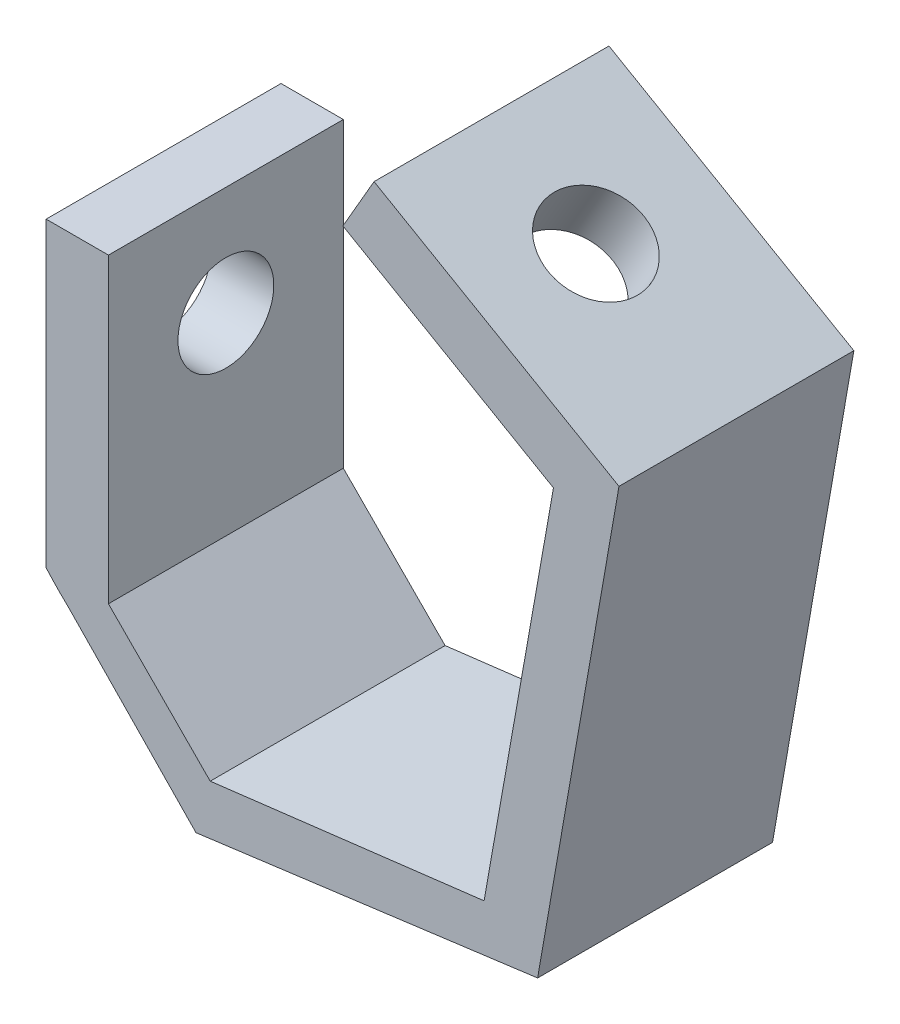
from build123d import *

# Parameters (mm, degrees)
BOSS_EXTRUDE3_DEPTH      = 49
SKETCH5_R                = 19
CUT_EXTRUDE2_DEPTH       = 49
SKETCH6_R                = 19
CUT_EXTRUDE3_DEPTH       = 49
SKETCH9_R                = 19
SKETCH9_R_2              = 10
BOSS_EXTRUDE4_DEPTH      = 13
SKETCH11_R               = 19
SKETCH11_R_2             = 10
BOSS_EXTRUDE5_DEPTH      = 13
BOSS_EXTRUDE6_DEPTH      = 58
CUT_EXTRUDE4_DEPTH       = 58
CUT_EXTRUDE5_DEPTH       = 184
BOSS_EXTRUDE7_DEPTH      = 3
BOSS_EXTRUDE7_DEPTH_BACK = 20
SKETCH18_W               = 9.328805748
SKETCH18_H               = 21.574307968
SKETCH18_W_2             = 22.550774564
SKETCH18_H_2             = 22.755980238
CUT_EXTRUDE6_DEPTH       = 535
CUT_EXTRUDE7_START       = -29
SKETCH19_R               = 10
CUT_EXTRUDE7_DEPTH       = 29
BOSS_EXTRUDE12_DEPTH     = 284
CUT_EXTRUDE9_DEPTH       = 284
BOSS_EXTRUDE13_START     = 154
BOSS_EXTRUDE13_DEPTH     = 154
SKETCH27_W               = 285.503749152
SKETCH27_H               = 203.662610786
CUT_EXTRUDE12_DEPTH      = 199
CUT_EXTRUDE13_DEPTH      = 73


with BuildPart() as part:
    # Sketch1 → Boss-Extrude3 (new body)
    with BuildSketch(Plane.XY):
        Polygon((7.505553499, -13), (50.508330249, 61.482994197), (-0.587168574, 90.982994197), (-7.087168574, 79.724663948), (32.75, 56.724663948), (0, 0), (-56, 0), (-56, 50), (-69, 50), (-69, -13), align=None)
    extrude(amount=BOSS_EXTRUDE3_DEPTH)

    # Sketch5 → Cut-Extrude2 (cut)
    with BuildSketch(Plane.ZY.offset(69)):
        with Locations((24.5, 25)):
            Circle(SKETCH5_R)
    extrude(amount=-CUT_EXTRUDE2_DEPTH, mode=Mode.SUBTRACT)

    # Sketch6 → Cut-Extrude3 (cut)
    with BuildSketch(Plane(origin=(39.25, 67.982994197, 0), x_dir=(0.8660254037844385, -0.5000000000000003, 0), z_dir=(0.5000000000000003, 0.8660254037844386, 0))):
        with Locations((-20.85, -24.5)):
            Circle(SKETCH6_R)
    extrude(amount=-CUT_EXTRUDE3_DEPTH, mode=Mode.SUBTRACT)

    # Sketch9 → Boss-Extrude4 (add)
    with BuildSketch(Plane(origin=(39.25, 67.982994197, 0), x_dir=(0.8660254037844385, -0.5000000000000003, 0), z_dir=(0.5000000000000003, 0.8660254037844386, 0))):
        with Locations((-20.85, -24.5)):
            Circle(SKETCH9_R)
        with Locations((-20.85, -24.5)):
            Circle(SKETCH9_R_2, mode=Mode.SUBTRACT)
    extrude(amount=-BOSS_EXTRUDE4_DEPTH)

    # Sketch11 → Boss-Extrude5 (add)
    with BuildSketch(Plane.ZY.offset(69)):
        with Locations((24.5, 25)):
            Circle(SKETCH11_R)
        with Locations((24.5, 25)):
            Circle(SKETCH11_R_2, mode=Mode.SUBTRACT)
    extrude(amount=-BOSS_EXTRUDE5_DEPTH)

    # Sketch12 → Boss-Extrude6 (add)
    with BuildSketch(Plane.XY.offset(49)):
        with BuildLine():
            Line((50.508330249, 61.482994197), (32.75, 56.724663948))
            ThreePointArc((32.75, 56.724663948), (16.910177277, -16.283097494), (-56, 0))
            Line((-56, 0), (-69, -13))
            ThreePointArc((-69, -13), (22.244773258, -26.285338417), (50.508330249, 61.482994197))
        make_face()
    extrude(amount=-BOSS_EXTRUDE6_DEPTH)

    # Sketch13 → Cut-Extrude4 (cut)
    with BuildSketch(Plane.XY.offset(49)):
        Polygon((32.75, 56.724663948), (39.316517917, 42.098206609), (7.505553499, -13), (-44.392822704, -13), (-56, 0), (0, 0), align=None)
    extrude(amount=-CUT_EXTRUDE4_DEPTH, mode=Mode.SUBTRACT)

    # Sketch16 → Cut-Extrude5 (cut)
    with BuildSketch(Plane.ZY.offset(69)):
        Polygon((-20.067670538, -13), (-20.067670538, 53.233474558), (-20.067670538, 98.990821442), (0, 98.990821442), (0, 53.233474558), (0, -13), (0, -105.844145432), (-20.067670538, -105.844145432), align=None)
    extrude(amount=-CUT_EXTRUDE5_DEPTH, mode=Mode.SUBTRACT)

    # Sketch17 → Boss-Extrude7 (add, two sides: drawn at the far end of the back side and taken through both)
    with BuildSketch(Plane.ZY.offset(69).offset(-BOSS_EXTRUDE7_DEPTH_BACK)):
        with BuildLine():
            ThreePointArc((34.433074801, 26.155), (24.5, 17.31), (14.566925199, 26.155))
            ThreePointArc((14.566925199, 26.155), (23.921531336, 15.01674532), (34.5, 25))
            ThreePointArc((34.5, 25), (34.48325468, 25.578468664), (34.433074801, 26.155))
        make_face()
    extrude(amount=BOSS_EXTRUDE7_DEPTH + BOSS_EXTRUDE7_DEPTH_BACK)

    # Sketch18 → Cut-Extrude6 (cut)
    with BuildSketch(Plane(origin=(0, 0, 0), x_dir=(-1, 0, 0), z_dir=(0, 0, -1))):
        with Locations((51.335597126, 20.158741433)):
            Rectangle(SKETCH18_W, SKETCH18_H)
        with Locations((80.275387282, 19.567905298)):
            Rectangle(SKETCH18_W_2, SKETCH18_H_2)
    extrude(amount=-CUT_EXTRUDE6_DEPTH, mode=Mode.SUBTRACT)

    # Sketch19 → Cut-Extrude7 (cut)
    with BuildSketch(Plane.ZY.offset(69).offset(CUT_EXTRUDE7_START)):
        with Locations((24.5, 27.31)):
            Circle(SKETCH19_R)
    extrude(amount=CUT_EXTRUDE7_DEPTH, mode=Mode.SUBTRACT)

    # Sketch21 → Boss-Extrude12 (add)
    with BuildSketch(Plane(origin=(0, 0, 0), x_dir=(-1, 0, 0), z_dir=(0, 0, -1))):
        Polygon((37.73885384, -45.225386792), (69, -13), (56, -13), (37.73885384, -31.461636701), (34.768910635, -34.431579906), (-22.363127135, -27.479360202), (-36.840667723, 54.362915837), (-48.129988201, 47.84502362), (-33.53595077, -35.840606547), align=None)
    extrude(amount=BOSS_EXTRUDE12_DEPTH)

    # Sketch23 → Cut-Extrude9 (cut)
    with BuildSketch(Plane(origin=(0, 0, 0), x_dir=(-1, 0, 0), z_dir=(0, 0, -1))):
        Polygon((-66.888962861, -18.747024991), (-37.413342103, -13.606736129), (-50.508330249, 61.482994197), (-79.983951007, 56.342705335), align=None)
        Polygon((56, 0), (-32.75, 56.724663948), (-35.984130282, 49.520865954), (-22.363127135, -27.479360202), (34.768910635, -34.431579906), (56, -13), align=None)
    extrude(amount=-CUT_EXTRUDE9_DEPTH, mode=Mode.SUBTRACT)

    # Sketch26 → Boss-Extrude13 (add)
    with BuildSketch(Plane.XY.offset(BOSS_EXTRUDE13_START)):
        with BuildLine():
            ThreePointArc((19.690093366, -27.804633355), (-24.032626354, -36.581822551), (-64.435496773, -17.705293954))
            Line((-64.435496773, -17.705293954), (-37.73885384, -45.225386792))
            Line((-37.73885384, -45.225386792), (33.53595077, -35.840606547))
            Line((33.53595077, -35.840606547), (48.129988201, 47.84502362))
            Line((48.129988201, 47.84502362), (35.984130282, 49.520865954))
            Line((35.984130282, 49.520865954), (22.363127135, -27.479360202))
            Line((22.363127135, -27.479360202), (19.690093366, -27.804633355))
        make_face()
    extrude(amount=-BOSS_EXTRUDE13_DEPTH)

    # Sketch27 → Cut-Extrude12 (cut)
    with BuildSketch(Plane(origin=(39.25, 67.982994197, 0), x_dir=(0.8660254037844385, -0.5000000000000003, 0), z_dir=(0.5000000000000003, 0.8660254037844386, 0))):
        with Locations((-30.536562906, -150.831305393)):
            Rectangle(SKETCH27_W, SKETCH27_H)
        Polygon((-173.288437482, 0), (177.590878736, 0), (177.590878736, 352.418162382), (-178.957111939, 352.418162382), (-178.957111939, 168.477547877), (-173.288437482, 168.477547877), align=None)
    extrude(amount=-CUT_EXTRUDE12_DEPTH, mode=Mode.SUBTRACT)

    # Sketch28 → Cut-Extrude13 (cut)
    with BuildSketch(Plane.XY.offset(49)):
        Polygon((32.75, 56.724663948), (36.840667723, 54.362915837), (35.984130282, 49.520865954), align=None)
    extrude(amount=-CUT_EXTRUDE13_DEPTH, mode=Mode.SUBTRACT)


solid = part.part
